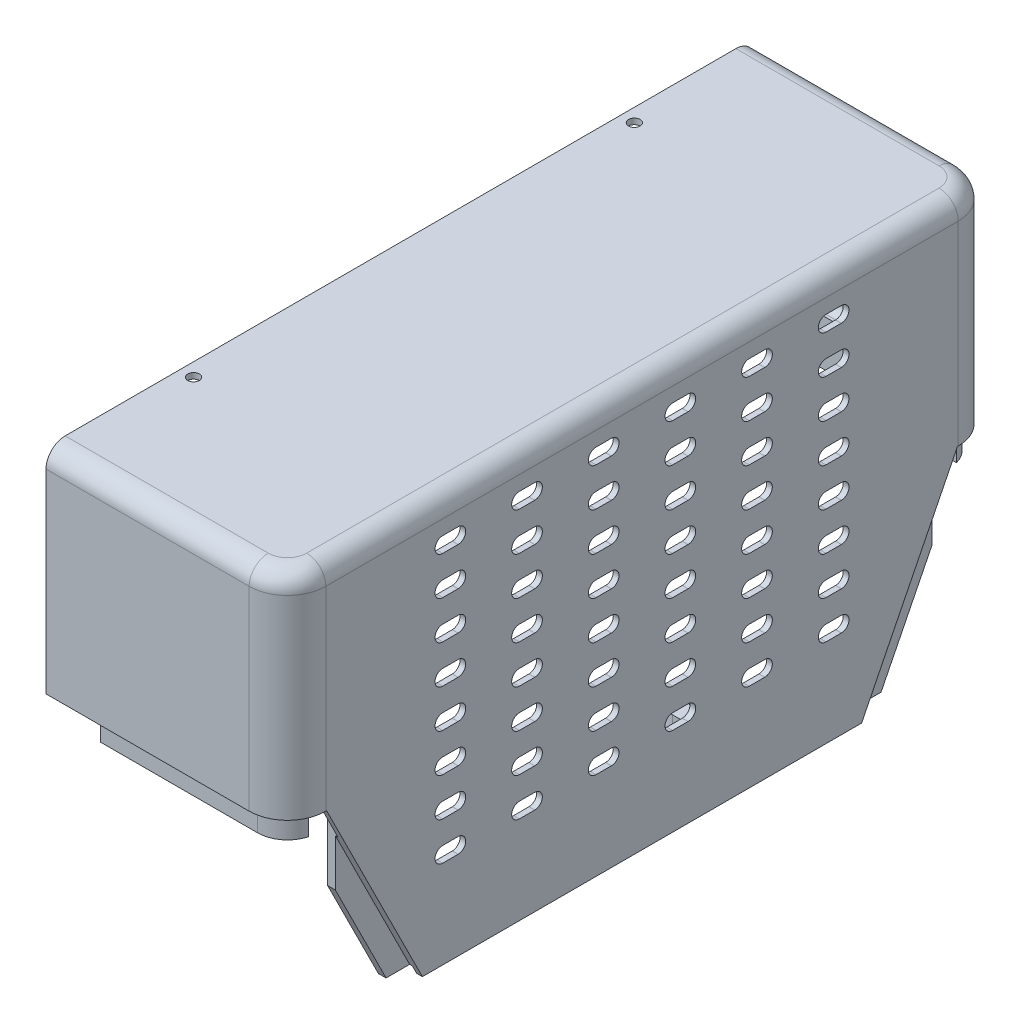
from build123d import *

# Parameters (mm, degrees)
SALIENTE_EXTRUIR1_DEPTH       = 1.5
SALIENTE_EXTRUIR2_DEPTH       = 54.3
CROQUIS3_W                    = 1.5
CROQUIS3_H                    = 164.6
SALIENTE_EXTRUIR3_DEPTH       = 50
CORTAR_EXTRUIR1_DEPTH         = 14.2
REDONDEO1_R                   = 5
SALIENTE_EXTRUIR4_DEPTH       = 6
SALIENTE_EXTRUIR5_DEPTH       = 2.7
REDONDEO3_R                   = 2
SALIENTE_EXTRUIR6_START       = -5
CROQUIS7_R                    = 1.5
SALIENTE_EXTRUIR6_DEPTH       = 13
REDONDEO4_R                   = 5
CORTAR_EXTRUIR4_DEPTH         = 6
SALIENTE_EXTRUIR7_DEPTH       = 6
SALIENTE_EXTRUIR8_DEPTH       = 2
REDONDEO5_R                   = 2
SALIENTE_EXTRUIR9_DEPTH       = 2.5
SALIENTE_EXTRUIR9_DEPTH_BACK  = 2.5
SALIENTE_EXTRUIR10_DEPTH      = 2.5
SALIENTE_EXTRUIR10_DEPTH_BACK = 2.5
SALIENTE_EXTRUIR11_DEPTH      = 2.5
SALIENTE_EXTRUIR11_DEPTH_BACK = 2.5
CROQUIS17_R                   = 1.5
CORTAR_EXTRUIR5_DEPTH         = 19.5


with BuildPart() as part:
    # Croquis1 → Saliente-Extruir1 (new body)
    with BuildSketch(Plane(origin=(0, 60.850502037, 0), x_dir=(1, 0, 0), z_dir=(0, 1, 0))):
        with BuildLine():
            Line((-39.035758582, -277.5), (-39.035758582, -272.5))
            Line((-39.035758582, -272.5), (-39.035758582, -97.5))
            Line((-39.035758582, -97.5), (-39.035758582, -92.5))
            Line((-39.035758582, -92.5), (13.964241418, -92.5))
            ThreePointArc((13.964241418, -92.5), (21.03530923, -95.428932188), (23.964241418, -102.5))
            Line((23.964241418, -102.5), (23.964241418, -127.500001305))
            Line((23.964241418, -127.500001305), (23.964241418, -242.5))
            Line((23.964241418, -242.5), (23.964241418, -267.5))
            ThreePointArc((23.964241418, -267.5), (21.03530923, -274.571067812), (13.964241418, -277.5))
            Line((13.964241418, -277.5), (-39.035758582, -277.5))
        make_face()
    extrude(amount=-SALIENTE_EXTRUIR1_DEPTH)

    # Croquis2 → Saliente-Extruir2 (add)
    with BuildSketch(Plane.XZ.offset(-59.350502037)):
        with BuildLine():
            Line((13.964241418, 92.5), (-39.035758582, 92.5))
            Line((-39.035758582, 92.5), (-39.035758582, 94))
            Line((-39.035758582, 94), (13.964241418, 94))
            ThreePointArc((13.964241418, 94), (19.974649059, 96.48959236), (22.464241418, 102.5))
            Line((22.464241418, 102.5), (22.464241418, 267.5))
            ThreePointArc((22.464241418, 267.5), (19.974649059, 273.51040764), (13.964241418, 276))
            Line((13.964241418, 276), (-39.035758582, 276))
            Line((-39.035758582, 276), (-39.035758582, 277.5))
            Line((-39.035758582, 277.5), (13.964241418, 277.5))
            ThreePointArc((13.964241418, 277.5), (21.03530923, 274.571067812), (23.964241418, 267.5))
            Line((23.964241418, 267.5), (23.964241418, 102.5))
            ThreePointArc((23.964241418, 102.5), (21.03530923, 95.428932188), (13.964241418, 92.5))
        make_face()
    extrude(amount=SALIENTE_EXTRUIR2_DEPTH)

    # Croquis3 → Saliente-Extruir3 (add)
    with BuildSketch(Plane.XZ.offset(-5.050502037)):
        with Locations((23.214241418, 185)):
            Rectangle(CROQUIS3_W, CROQUIS3_H)
    extrude(amount=SALIENTE_EXTRUIR3_DEPTH)

    # Croquis4 → Cortar-Extruir1 (cut)
    with BuildSketch(Plane(origin=(23.964241418, 0, 0), x_dir=(0, 0, -1), z_dir=(1, 0, 0))):
        Polygon((-267.3, 5.050502037), (-242.3, -44.949497963), (-280.978278241, -56.836077199), align=None)
        Polygon((-102.7, 5.050502037), (-131.248203049, -52.045901079), (-85.324020241, -44.887249587), align=None)
    extrude(amount=-CORTAR_EXTRUIR1_DEPTH, mode=Mode.SUBTRACT)

    # Redondeo1
    redondeo1_edges = [part.edges().sort_by_distance(p)[0] for p in [
        (-12.535758582, 60.850502037, 92.5),
        (21.03530923, 60.850502037, 95.428932188),
        (23.964241418, 60.850502037, 185),
        (21.03530923, 60.850502037, 274.571067812),
        (-12.535758582, 60.850502037, 277.5),
        (-12.535758582, 59.350502037, 94),
        (19.974649059, 59.350502037, 96.48959236),
        (22.464241418, 59.350502037, 185),
        (19.974649059, 59.350502037, 273.51040764),
        (-12.535758582, 59.350502037, 276),
    ]]
    fillet(redondeo1_edges, radius=REDONDEO1_R)

    # Croquis5 → Saliente-Extruir4 (add)
    with BuildSketch(Plane.XZ.offset(-5.050502037)):
        with BuildLine():
            Line((-27.035758582, 94), (13.964241418, 94))
            ThreePointArc((13.964241418, 94), (19.220190429, 95.819805392), (22.225597239, 100.5))
            Line((22.225597239, 100.5), (19.408504454, 100.5))
            ThreePointArc((19.408504454, 100.5), (17.283879953, 97.74395122), (13.964241418, 96.7))
            Line((13.964241418, 96.7), (-27.035758582, 96.7))
            Line((-27.035758582, 96.7), (-27.035758582, 94))
        make_face()
        with BuildLine():
            Line((13.964241418, 276), (-27.035758582, 276))
            Line((-27.035758582, 276), (-27.035758582, 273.3))
            Line((-27.035758582, 273.3), (13.964241418, 273.3))
            ThreePointArc((13.964241418, 273.3), (17.283879953, 272.25604878), (19.408504454, 269.5))
            Line((19.408504454, 269.5), (22.225597239, 269.5))
            ThreePointArc((22.225597239, 269.5), (19.220190429, 274.180194608), (13.964241418, 276))
        make_face()
    extrude(amount=-SALIENTE_EXTRUIR4_DEPTH)

    # Croquis6 → Saliente-Extruir5 (add)
    with BuildSketch(Plane.ZY.offset(-22.464241418)):
        Polygon((243.418033989, -42.713429985), (262.827864045, -3.893769873), (262.827864045, 7.286570015), (237.827864045, -42.713429985), align=None)
        Polygon((107.172135908, -3.893769312), (126.581967212, -42.713429892), (132.172137214, -42.713429892), (107.172135908, 7.286570108), align=None)
    extrude(amount=SALIENTE_EXTRUIR5_DEPTH)

    # Redondeo3
    redondeo3_edges = [part.edges().sort_by_distance(p)[0] for p in [
        (22.464241418, -17.713429985, 250.327864045),
        (22.464241418, -17.713429892, 119.672136561),
    ]]
    fillet(redondeo3_edges, radius=REDONDEO3_R)

    # Croquis7 → Saliente-Extruir6 (add)
    with BuildSketch(Plane.XZ.offset(44.949497963).offset(SALIENTE_EXTRUIR6_START)):
        with BuildLine():
            Line((15.405698528, 168.5), (22.642630472, 168.5))
            Line((22.642630472, 168.5), (22.642630472, 156.5))
            Line((22.642630472, 156.5), (15.405698528, 156.5))
            ThreePointArc((15.405698528, 156.5), (9.405698528, 162.5), (15.405698528, 168.5))
        make_face()
        with Locations((15.405698528, 162.5)):
            Circle(CROQUIS7_R, mode=Mode.SUBTRACT)
    extrude(amount=-SALIENTE_EXTRUIR6_DEPTH)

    # Redondeo4
    redondeo4_edges = [part.edges().sort_by_distance(p)[0] for p in [
        (22.464241418, -26.949497963, 162.5),
    ]]
    fillet(redondeo4_edges, radius=REDONDEO4_R)

    # Croquis11 → Cortar-Extruir4 (cut)
    with BuildSketch(Plane(origin=(23.964241418, 0, 0), x_dir=(0, 0, -1), z_dir=(1, 0, 0))):
        with BuildLine():
            Line((-193.000000653, -21.949497963), (-197.000000653, -21.949497963))
            ThreePointArc((-197.000000653, -21.949497963), (-199.000000653, -19.949497963), (-197.000000653, -17.949497963))
            Line((-197.000000653, -17.949497963), (-193.000000653, -17.949497963))
            ThreePointArc((-193.000000653, -17.949497963), (-191.000000653, -19.949497963), (-193.000000653, -21.949497963))
        make_face()
        with BuildLine():
            Line((-213.000000653, -21.949497963), (-217.000000653, -21.949497963))
            ThreePointArc((-217.000000653, -21.949497963), (-219.000000653, -19.949497963), (-217.000000653, -17.949497963))
            Line((-217.000000653, -17.949497963), (-213.000000653, -17.949497963))
            ThreePointArc((-213.000000653, -17.949497963), (-211.000000653, -19.949497963), (-213.000000653, -21.949497963))
        make_face()
        with BuildLine():
            Line((-233.000000653, -21.949497963), (-237.000000653, -21.949497963))
            ThreePointArc((-237.000000653, -21.949497963), (-239.000000653, -19.949497963), (-237.000000653, -17.949497963))
            Line((-237.000000653, -17.949497963), (-233.000000653, -17.949497963))
            ThreePointArc((-233.000000653, -17.949497963), (-231.000000653, -19.949497963), (-233.000000653, -21.949497963))
        make_face()
        with BuildLine():
            Line((-213.000000653, -11.949497963), (-217.000000653, -11.949497963))
            ThreePointArc((-217.000000653, -11.949497963), (-219.000000653, -9.949497963), (-217.000000653, -7.949497963))
            Line((-217.000000653, -7.949497963), (-213.000000653, -7.949497963))
            ThreePointArc((-213.000000653, -7.949497963), (-211.000000653, -9.949497963), (-213.000000653, -11.949497963))
        make_face()
        with BuildLine():
            Line((-233.000000653, -11.949497963), (-237.000000653, -11.949497963))
            ThreePointArc((-237.000000653, -11.949497963), (-239.000000653, -9.949497963), (-237.000000653, -7.949497963))
            Line((-237.000000653, -7.949497963), (-233.000000653, -7.949497963))
            ThreePointArc((-233.000000653, -7.949497963), (-231.000000653, -9.949497963), (-233.000000653, -11.949497963))
        make_face()
        with BuildLine():
            Line((-213.000000653, -1.949497963), (-217.000000653, -1.949497963))
            ThreePointArc((-217.000000653, -1.949497963), (-219.000000653, 0.050502037), (-217.000000653, 2.050502037))
            Line((-217.000000653, 2.050502037), (-213.000000653, 2.050502037))
            ThreePointArc((-213.000000653, 2.050502037), (-211.000000653, 0.050502037), (-213.000000653, -1.949497963))
        make_face()
        with BuildLine():
            Line((-233.000000653, -1.949497963), (-237.000000653, -1.949497963))
            ThreePointArc((-237.000000653, -1.949497963), (-239.000000653, 0.050502037), (-237.000000653, 2.050502037))
            Line((-237.000000653, 2.050502037), (-233.000000653, 2.050502037))
            ThreePointArc((-233.000000653, 2.050502037), (-231.000000653, 0.050502037), (-233.000000653, -1.949497963))
        make_face()
        with BuildLine():
            Line((-213.000000653, 8.050502037), (-217.000000653, 8.050502037))
            ThreePointArc((-217.000000653, 8.050502037), (-219.000000653, 10.050502037), (-217.000000653, 12.050502037))
            Line((-217.000000653, 12.050502037), (-213.000000653, 12.050502037))
            ThreePointArc((-213.000000653, 12.050502037), (-211.000000653, 10.050502037), (-213.000000653, 8.050502037))
        make_face()
        with BuildLine():
            Line((-233.000000653, 8.050502037), (-237.000000653, 8.050502037))
            ThreePointArc((-237.000000653, 8.050502037), (-239.000000653, 10.050502037), (-237.000000653, 12.050502037))
            Line((-237.000000653, 12.050502037), (-233.000000653, 12.050502037))
            ThreePointArc((-233.000000653, 12.050502037), (-231.000000653, 10.050502037), (-233.000000653, 8.050502037))
        make_face()
        with BuildLine():
            Line((-213.000000653, 18.050502037), (-217.000000653, 18.050502037))
            ThreePointArc((-217.000000653, 18.050502037), (-219.000000653, 20.050502037), (-217.000000653, 22.050502037))
            Line((-217.000000653, 22.050502037), (-213.000000653, 22.050502037))
            ThreePointArc((-213.000000653, 22.050502037), (-211.000000653, 20.050502037), (-213.000000653, 18.050502037))
        make_face()
        with BuildLine():
            Line((-233.000000653, 18.050502037), (-237.000000653, 18.050502037))
            ThreePointArc((-237.000000653, 18.050502037), (-239.000000653, 20.050502037), (-237.000000653, 22.050502037))
            Line((-237.000000653, 22.050502037), (-233.000000653, 22.050502037))
            ThreePointArc((-233.000000653, 22.050502037), (-231.000000653, 20.050502037), (-233.000000653, 18.050502037))
        make_face()
        with BuildLine():
            Line((-213.000000653, 28.050502037), (-217.000000653, 28.050502037))
            ThreePointArc((-217.000000653, 28.050502037), (-219.000000653, 30.050502037), (-217.000000653, 32.050502037))
            Line((-217.000000653, 32.050502037), (-213.000000653, 32.050502037))
            ThreePointArc((-213.000000653, 32.050502037), (-211.000000653, 30.050502037), (-213.000000653, 28.050502037))
        make_face()
        with BuildLine():
            Line((-233.000000653, 28.050502037), (-237.000000653, 28.050502037))
            ThreePointArc((-237.000000653, 28.050502037), (-239.000000653, 30.050502037), (-237.000000653, 32.050502037))
            Line((-237.000000653, 32.050502037), (-233.000000653, 32.050502037))
            ThreePointArc((-233.000000653, 32.050502037), (-231.000000653, 30.050502037), (-233.000000653, 28.050502037))
        make_face()
        with BuildLine():
            Line((-213.000000653, 38.050502037), (-217.000000653, 38.050502037))
            ThreePointArc((-217.000000653, 38.050502037), (-219.000000653, 40.050502037), (-217.000000653, 42.050502037))
            Line((-217.000000653, 42.050502037), (-213.000000653, 42.050502037))
            ThreePointArc((-213.000000653, 42.050502037), (-211.000000653, 40.050502037), (-213.000000653, 38.050502037))
        make_face()
        with BuildLine():
            Line((-233.000000653, 38.050502037), (-237.000000653, 38.050502037))
            ThreePointArc((-237.000000653, 38.050502037), (-239.000000653, 40.050502037), (-237.000000653, 42.050502037))
            Line((-237.000000653, 42.050502037), (-233.000000653, 42.050502037))
            ThreePointArc((-233.000000653, 42.050502037), (-231.000000653, 40.050502037), (-233.000000653, 38.050502037))
        make_face()
        with BuildLine():
            Line((-213.000000653, 48.050502037), (-217.000000653, 48.050502037))
            ThreePointArc((-217.000000653, 48.050502037), (-219.000000653, 50.050502037), (-217.000000653, 52.050502037))
            Line((-217.000000653, 52.050502037), (-213.000000653, 52.050502037))
            ThreePointArc((-213.000000653, 52.050502037), (-211.000000653, 50.050502037), (-213.000000653, 48.050502037))
        make_face()
        with BuildLine():
            Line((-233.000000653, 48.050502037), (-237.000000653, 48.050502037))
            ThreePointArc((-237.000000653, 48.050502037), (-239.000000653, 50.050502037), (-237.000000653, 52.050502037))
            Line((-237.000000653, 52.050502037), (-233.000000653, 52.050502037))
            ThreePointArc((-233.000000653, 52.050502037), (-231.000000653, 50.050502037), (-233.000000653, 48.050502037))
        make_face()
        with BuildLine():
            Line((-193.000000653, -11.949497963), (-197.000000653, -11.949497963))
            ThreePointArc((-197.000000653, -11.949497963), (-199.000000653, -9.949497963), (-197.000000653, -7.949497963))
            Line((-197.000000653, -7.949497963), (-193.000000653, -7.949497963))
            ThreePointArc((-193.000000653, -7.949497963), (-191.000000653, -9.949497963), (-193.000000653, -11.949497963))
        make_face()
        with BuildLine():
            Line((-193.000000653, -1.949497963), (-197.000000653, -1.949497963))
            ThreePointArc((-197.000000653, -1.949497963), (-199.000000653, 0.050502037), (-197.000000653, 2.050502037))
            Line((-197.000000653, 2.050502037), (-193.000000653, 2.050502037))
            ThreePointArc((-193.000000653, 2.050502037), (-191.000000653, 0.050502037), (-193.000000653, -1.949497963))
        make_face()
        with BuildLine():
            Line((-193.000000653, 8.050502037), (-197.000000653, 8.050502037))
            ThreePointArc((-197.000000653, 8.050502037), (-199.000000653, 10.050502037), (-197.000000653, 12.050502037))
            Line((-197.000000653, 12.050502037), (-193.000000653, 12.050502037))
            ThreePointArc((-193.000000653, 12.050502037), (-191.000000653, 10.050502037), (-193.000000653, 8.050502037))
        make_face()
        with BuildLine():
            Line((-193.000000653, 18.050502037), (-197.000000653, 18.050502037))
            ThreePointArc((-197.000000653, 18.050502037), (-199.000000653, 20.050502037), (-197.000000653, 22.050502037))
            Line((-197.000000653, 22.050502037), (-193.000000653, 22.050502037))
            ThreePointArc((-193.000000653, 22.050502037), (-191.000000653, 20.050502037), (-193.000000653, 18.050502037))
        make_face()
        with BuildLine():
            Line((-193.000000653, 28.050502037), (-197.000000653, 28.050502037))
            ThreePointArc((-197.000000653, 28.050502037), (-199.000000653, 30.050502037), (-197.000000653, 32.050502037))
            Line((-197.000000653, 32.050502037), (-193.000000653, 32.050502037))
            ThreePointArc((-193.000000653, 32.050502037), (-191.000000653, 30.050502037), (-193.000000653, 28.050502037))
        make_face()
        with BuildLine():
            Line((-193.000000653, 38.050502037), (-197.000000653, 38.050502037))
            ThreePointArc((-197.000000653, 38.050502037), (-199.000000653, 40.050502037), (-197.000000653, 42.050502037))
            Line((-197.000000653, 42.050502037), (-193.000000653, 42.050502037))
            ThreePointArc((-193.000000653, 42.050502037), (-191.000000653, 40.050502037), (-193.000000653, 38.050502037))
        make_face()
        with BuildLine():
            Line((-193.000000653, 48.050502037), (-197.000000653, 48.050502037))
            ThreePointArc((-197.000000653, 48.050502037), (-199.000000653, 50.050502037), (-197.000000653, 52.050502037))
            Line((-197.000000653, 52.050502037), (-193.000000653, 52.050502037))
            ThreePointArc((-193.000000653, 52.050502037), (-191.000000653, 50.050502037), (-193.000000653, 48.050502037))
        make_face()
        with BuildLine():
            Line((-177.000000653, 48.050502037), (-173.000000653, 48.050502037))
            ThreePointArc((-173.000000653, 48.050502037), (-171.000000653, 50.050502037), (-173.000000653, 52.050502037))
            Line((-173.000000653, 52.050502037), (-177.000000653, 52.050502037))
            ThreePointArc((-177.000000653, 52.050502037), (-179.000000653, 50.050502037), (-177.000000653, 48.050502037))
        make_face()
        with BuildLine():
            Line((-177.000000653, 38.050502037), (-173.000000653, 38.050502037))
            ThreePointArc((-173.000000653, 38.050502037), (-171.000000653, 40.050502037), (-173.000000653, 42.050502037))
            Line((-173.000000653, 42.050502037), (-177.000000653, 42.050502037))
            ThreePointArc((-177.000000653, 42.050502037), (-179.000000653, 40.050502037), (-177.000000653, 38.050502037))
        make_face()
        with BuildLine():
            Line((-177.000000653, 28.050502037), (-173.000000653, 28.050502037))
            ThreePointArc((-173.000000653, 28.050502037), (-171.000000653, 30.050502037), (-173.000000653, 32.050502037))
            Line((-173.000000653, 32.050502037), (-177.000000653, 32.050502037))
            ThreePointArc((-177.000000653, 32.050502037), (-179.000000653, 30.050502037), (-177.000000653, 28.050502037))
        make_face()
        with BuildLine():
            Line((-177.000000653, 18.050502037), (-173.000000653, 18.050502037))
            ThreePointArc((-173.000000653, 18.050502037), (-171.000000653, 20.050502037), (-173.000000653, 22.050502037))
            Line((-173.000000653, 22.050502037), (-177.000000653, 22.050502037))
            ThreePointArc((-177.000000653, 22.050502037), (-179.000000653, 20.050502037), (-177.000000653, 18.050502037))
        make_face()
        with BuildLine():
            Line((-177.000000653, 8.050502037), (-173.000000653, 8.050502037))
            ThreePointArc((-173.000000653, 8.050502037), (-171.000000653, 10.050502037), (-173.000000653, 12.050502037))
            Line((-173.000000653, 12.050502037), (-177.000000653, 12.050502037))
            ThreePointArc((-177.000000653, 12.050502037), (-179.000000653, 10.050502037), (-177.000000653, 8.050502037))
        make_face()
        with BuildLine():
            Line((-177.000000653, -1.949497963), (-173.000000653, -1.949497963))
            ThreePointArc((-173.000000653, -1.949497963), (-171.000000653, 0.050502037), (-173.000000653, 2.050502037))
            Line((-173.000000653, 2.050502037), (-177.000000653, 2.050502037))
            ThreePointArc((-177.000000653, 2.050502037), (-179.000000653, 0.050502037), (-177.000000653, -1.949497963))
        make_face()
        with BuildLine():
            Line((-177.000000653, -11.949497963), (-173.000000653, -11.949497963))
            ThreePointArc((-173.000000653, -11.949497963), (-171.000000653, -9.949497963), (-173.000000653, -7.949497963))
            Line((-173.000000653, -7.949497963), (-177.000000653, -7.949497963))
            ThreePointArc((-177.000000653, -7.949497963), (-179.000000653, -9.949497963), (-177.000000653, -11.949497963))
        make_face()
        with BuildLine():
            Line((-137.000000653, 48.050502037), (-133.000000653, 48.050502037))
            ThreePointArc((-133.000000653, 48.050502037), (-131.000000653, 50.050502037), (-133.000000653, 52.050502037))
            Line((-133.000000653, 52.050502037), (-137.000000653, 52.050502037))
            ThreePointArc((-137.000000653, 52.050502037), (-139.000000653, 50.050502037), (-137.000000653, 48.050502037))
        make_face()
        with BuildLine():
            Line((-157.000000653, 48.050502037), (-153.000000653, 48.050502037))
            ThreePointArc((-153.000000653, 48.050502037), (-151.000000653, 50.050502037), (-153.000000653, 52.050502037))
            Line((-153.000000653, 52.050502037), (-157.000000653, 52.050502037))
            ThreePointArc((-157.000000653, 52.050502037), (-159.000000653, 50.050502037), (-157.000000653, 48.050502037))
        make_face()
        with BuildLine():
            Line((-137.000000653, 38.050502037), (-133.000000653, 38.050502037))
            ThreePointArc((-133.000000653, 38.050502037), (-131.000000653, 40.050502037), (-133.000000653, 42.050502037))
            Line((-133.000000653, 42.050502037), (-137.000000653, 42.050502037))
            ThreePointArc((-137.000000653, 42.050502037), (-139.000000653, 40.050502037), (-137.000000653, 38.050502037))
        make_face()
        with BuildLine():
            Line((-157.000000653, 38.050502037), (-153.000000653, 38.050502037))
            ThreePointArc((-153.000000653, 38.050502037), (-151.000000653, 40.050502037), (-153.000000653, 42.050502037))
            Line((-153.000000653, 42.050502037), (-157.000000653, 42.050502037))
            ThreePointArc((-157.000000653, 42.050502037), (-159.000000653, 40.050502037), (-157.000000653, 38.050502037))
        make_face()
        with BuildLine():
            Line((-137.000000653, 28.050502037), (-133.000000653, 28.050502037))
            ThreePointArc((-133.000000653, 28.050502037), (-131.000000653, 30.050502037), (-133.000000653, 32.050502037))
            Line((-133.000000653, 32.050502037), (-137.000000653, 32.050502037))
            ThreePointArc((-137.000000653, 32.050502037), (-139.000000653, 30.050502037), (-137.000000653, 28.050502037))
        make_face()
        with BuildLine():
            Line((-157.000000653, 28.050502037), (-153.000000653, 28.050502037))
            ThreePointArc((-153.000000653, 28.050502037), (-151.000000653, 30.050502037), (-153.000000653, 32.050502037))
            Line((-153.000000653, 32.050502037), (-157.000000653, 32.050502037))
            ThreePointArc((-157.000000653, 32.050502037), (-159.000000653, 30.050502037), (-157.000000653, 28.050502037))
        make_face()
        with BuildLine():
            Line((-137.000000653, 18.050502037), (-133.000000653, 18.050502037))
            ThreePointArc((-133.000000653, 18.050502037), (-131.000000653, 20.050502037), (-133.000000653, 22.050502037))
            Line((-133.000000653, 22.050502037), (-137.000000653, 22.050502037))
            ThreePointArc((-137.000000653, 22.050502037), (-139.000000653, 20.050502037), (-137.000000653, 18.050502037))
        make_face()
        with BuildLine():
            Line((-157.000000653, 18.050502037), (-153.000000653, 18.050502037))
            ThreePointArc((-153.000000653, 18.050502037), (-151.000000653, 20.050502037), (-153.000000653, 22.050502037))
            Line((-153.000000653, 22.050502037), (-157.000000653, 22.050502037))
            ThreePointArc((-157.000000653, 22.050502037), (-159.000000653, 20.050502037), (-157.000000653, 18.050502037))
        make_face()
        with BuildLine():
            Line((-137.000000653, 8.050502037), (-133.000000653, 8.050502037))
            ThreePointArc((-133.000000653, 8.050502037), (-131.000000653, 10.050502037), (-133.000000653, 12.050502037))
            Line((-133.000000653, 12.050502037), (-137.000000653, 12.050502037))
            ThreePointArc((-137.000000653, 12.050502037), (-139.000000653, 10.050502037), (-137.000000653, 8.050502037))
        make_face()
        with BuildLine():
            Line((-157.000000653, 8.050502037), (-153.000000653, 8.050502037))
            ThreePointArc((-153.000000653, 8.050502037), (-151.000000653, 10.050502037), (-153.000000653, 12.050502037))
            Line((-153.000000653, 12.050502037), (-157.000000653, 12.050502037))
            ThreePointArc((-157.000000653, 12.050502037), (-159.000000653, 10.050502037), (-157.000000653, 8.050502037))
        make_face()
        with BuildLine():
            Line((-137.000000653, -1.949497963), (-133.000000653, -1.949497963))
            ThreePointArc((-133.000000653, -1.949497963), (-131.000000653, 0.050502037), (-133.000000653, 2.050502037))
            Line((-133.000000653, 2.050502037), (-137.000000653, 2.050502037))
            ThreePointArc((-137.000000653, 2.050502037), (-139.000000653, 0.050502037), (-137.000000653, -1.949497963))
        make_face()
        with BuildLine():
            Line((-157.000000653, -1.949497963), (-153.000000653, -1.949497963))
            ThreePointArc((-153.000000653, -1.949497963), (-151.000000653, 0.050502037), (-153.000000653, 2.050502037))
            Line((-153.000000653, 2.050502037), (-157.000000653, 2.050502037))
            ThreePointArc((-157.000000653, 2.050502037), (-159.000000653, 0.050502037), (-157.000000653, -1.949497963))
        make_face()
        with BuildLine():
            Line((-137.000000653, -11.949497963), (-133.000000653, -11.949497963))
            ThreePointArc((-133.000000653, -11.949497963), (-131.000000653, -9.949497963), (-133.000000653, -7.949497963))
            Line((-133.000000653, -7.949497963), (-137.000000653, -7.949497963))
            ThreePointArc((-137.000000653, -7.949497963), (-139.000000653, -9.949497963), (-137.000000653, -11.949497963))
        make_face()
        with BuildLine():
            Line((-157.000000653, -11.949497963), (-153.000000653, -11.949497963))
            ThreePointArc((-153.000000653, -11.949497963), (-151.000000653, -9.949497963), (-153.000000653, -7.949497963))
            Line((-153.000000653, -7.949497963), (-157.000000653, -7.949497963))
            ThreePointArc((-157.000000653, -7.949497963), (-159.000000653, -9.949497963), (-157.000000653, -11.949497963))
        make_face()
        with BuildLine():
            Line((-137.000000653, -21.949497963), (-133.000000653, -21.949497963))
            ThreePointArc((-133.000000653, -21.949497963), (-131.000000653, -19.949497963), (-133.000000653, -17.949497963))
            Line((-133.000000653, -17.949497963), (-137.000000653, -17.949497963))
            ThreePointArc((-137.000000653, -17.949497963), (-139.000000653, -19.949497963), (-137.000000653, -21.949497963))
        make_face()
        with BuildLine():
            Line((-157.000000653, -21.949497963), (-153.000000653, -21.949497963))
            ThreePointArc((-153.000000653, -21.949497963), (-151.000000653, -19.949497963), (-153.000000653, -17.949497963))
            Line((-153.000000653, -17.949497963), (-157.000000653, -17.949497963))
            ThreePointArc((-157.000000653, -17.949497963), (-159.000000653, -19.949497963), (-157.000000653, -21.949497963))
        make_face()
        with BuildLine():
            Line((-177.000000653, -21.949497963), (-173.000000653, -21.949497963))
            ThreePointArc((-173.000000653, -21.949497963), (-171.000000653, -19.949497963), (-173.000000653, -17.949497963))
            Line((-173.000000653, -17.949497963), (-177.000000653, -17.949497963))
            ThreePointArc((-177.000000653, -17.949497963), (-179.000000653, -19.949497963), (-177.000000653, -21.949497963))
        make_face()
    extrude(amount=-CORTAR_EXTRUIR4_DEPTH, mode=Mode.SUBTRACT)

    # Croquis12 → Saliente-Extruir7 (add)
    with BuildSketch(Plane.XZ.offset(-5.050502037)):
        with BuildLine():
            Line((13.964241418, 275.3), (-27.035758582, 275.3))
            Line((-27.035758582, 275.3), (-27.035758582, 273.3))
            Line((-27.035758582, 273.3), (13.964241418, 273.3))
            ThreePointArc((13.964241418, 273.3), (17.283879953, 272.25604878), (19.408504454, 269.5))
            Line((19.408504454, 269.5), (21.503472148, 269.5))
            ThreePointArc((21.503472148, 269.5), (18.720290199, 273.682232606), (13.964241418, 275.3))
        make_face()
        with BuildLine():
            Line((13.964241418, 94.7), (-27.035758582, 94.7))
            Line((-27.035758582, 94.7), (-27.035758582, 96.7))
            Line((-27.035758582, 96.7), (13.964241418, 96.7))
            ThreePointArc((13.964241418, 96.7), (17.283879953, 97.74395122), (19.408504454, 100.5))
            Line((19.408504454, 100.5), (21.503472148, 100.5))
            ThreePointArc((21.503472148, 100.5), (18.720290199, 96.317767394), (13.964241418, 94.7))
        make_face()
    extrude(amount=SALIENTE_EXTRUIR7_DEPTH)

    # Croquis13 → Saliente-Extruir8 (add)
    with BuildSketch(Plane.ZY.offset(-19.764241418)):
        Polygon((107.172135908, -3.893769312), (107.172135908, -16.192142675), (120.432780209, -42.713429892), (126.581967212, -42.713429892), align=None)
        Polygon((243.418033989, -42.713429985), (262.827864045, -3.893769873), (262.827864045, -16.192143749), (249.567220927, -42.713429985), align=None)
    extrude(amount=-SALIENTE_EXTRUIR8_DEPTH)

    # Redondeo5
    redondeo5_edges = [part.edges().sort_by_distance(p)[0] for p in [
        (19.220190429, 11.050502037, 95.819805392),
        (-6.535758582, 11.050502037, 94),
        (19.220190429, 11.050502037, 274.180194608),
        (-6.535758582, 11.050502037, 276),
    ]]
    fillet(redondeo5_edges, radius=REDONDEO5_R)

    # Croquis14 → Saliente-Extruir9 (add, two sides)
    with BuildSketch(Plane.ZY.offset(7.535758582)) as saliente_extruir9_sk:
        with BuildLine():
            Line((276, 8.938284618), (276, 54.350502037))
            ThreePointArc((276, 54.350502037), (274.535533906, 57.886035943), (271, 59.350502037))
            Line((271, 59.350502037), (99, 59.350502037))
            ThreePointArc((99, 59.350502037), (95.464466094, 57.886035943), (94, 54.350502037))
            Line((94, 54.350502037), (94, 8.938284618))
            Line((94, 8.938284618), (96, 8.938284618))
            Line((96, 8.938284618), (96, 54.350502037))
            ThreePointArc((96, 54.350502037), (96.878679656, 56.471822381), (99, 57.350502037))
            Line((99, 57.350502037), (271, 57.350502037))
            ThreePointArc((271, 57.350502037), (273.121320344, 56.471822381), (274, 54.350502037))
            Line((274, 54.350502037), (274, 8.938284618))
            Line((274, 8.938284618), (276, 8.938284618))
        make_face()
    extrude(amount=SALIENTE_EXTRUIR9_DEPTH)
    extrude(saliente_extruir9_sk.sketch, amount=-SALIENTE_EXTRUIR9_DEPTH_BACK)

    # Croquis15 → Saliente-Extruir10 (add, two sides)
    with BuildSketch(Plane(origin=(0, 0, 165), x_dir=(-1, 0, 0), z_dir=(0, 0, -1))) as saliente_extruir10_sk:
        with BuildLine():
            Line((5.035758582, 59.350502037), (-17.464241418, 59.350502037))
            ThreePointArc((-17.464241418, 59.350502037), (-20.999775324, 57.886035943), (-22.464241418, 54.350502037))
            Line((-22.464241418, 54.350502037), (-22.464241418, -28.226376618))
            Line((-22.464241418, -28.226376618), (-20.464241418, -28.226376618))
            Line((-20.464241418, -28.226376618), (-20.464241418, 54.350502037))
            ThreePointArc((-20.464241418, 54.350502037), (-19.585561762, 56.471822381), (-17.464241418, 57.350502037))
            Line((-17.464241418, 57.350502037), (5.035758582, 57.350502037))
            Line((5.035758582, 57.350502037), (5.035758582, 59.350502037))
        make_face()
    extrude(amount=SALIENTE_EXTRUIR10_DEPTH)
    extrude(saliente_extruir10_sk.sketch, amount=-SALIENTE_EXTRUIR10_DEPTH_BACK)

    # Croquis16 → Saliente-Extruir11 (add, two sides)
    with BuildSketch(Plane.XY.offset(205)) as saliente_extruir11_sk:
        with BuildLine():
            Line((-5.035758582, 59.350502037), (17.464241418, 59.350502037))
            ThreePointArc((17.464241418, 59.350502037), (20.999775324, 57.886035943), (22.464241418, 54.350502037))
            Line((22.464241418, 54.350502037), (22.464241418, -36.073101804))
            Line((22.464241418, -36.073101804), (20.464241418, -36.073101804))
            Line((20.464241418, -36.073101804), (20.464241418, 54.350502037))
            ThreePointArc((20.464241418, 54.350502037), (19.585561762, 56.471822381), (17.464241418, 57.350502037))
            Line((17.464241418, 57.350502037), (-5.035758582, 57.350502037))
            Line((-5.035758582, 57.350502037), (-5.035758582, 59.350502037))
        make_face()
    extrude(amount=SALIENTE_EXTRUIR11_DEPTH)
    extrude(saliente_extruir11_sk.sketch, amount=-SALIENTE_EXTRUIR11_DEPTH_BACK)

    # Croquis17 → Cortar-Extruir5 (cut)
    with BuildSketch(Plane(origin=(0, 60.850502037, 0), x_dir=(1, 0, 0), z_dir=(0, 1, 0))):
        with Locations((-35.535758582, -242.5)):
            Circle(CROQUIS17_R)
        with Locations((-35.535758582, -127.5)):
            Circle(CROQUIS17_R)
    extrude(amount=-CORTAR_EXTRUIR5_DEPTH, mode=Mode.SUBTRACT)


solid = part.part
